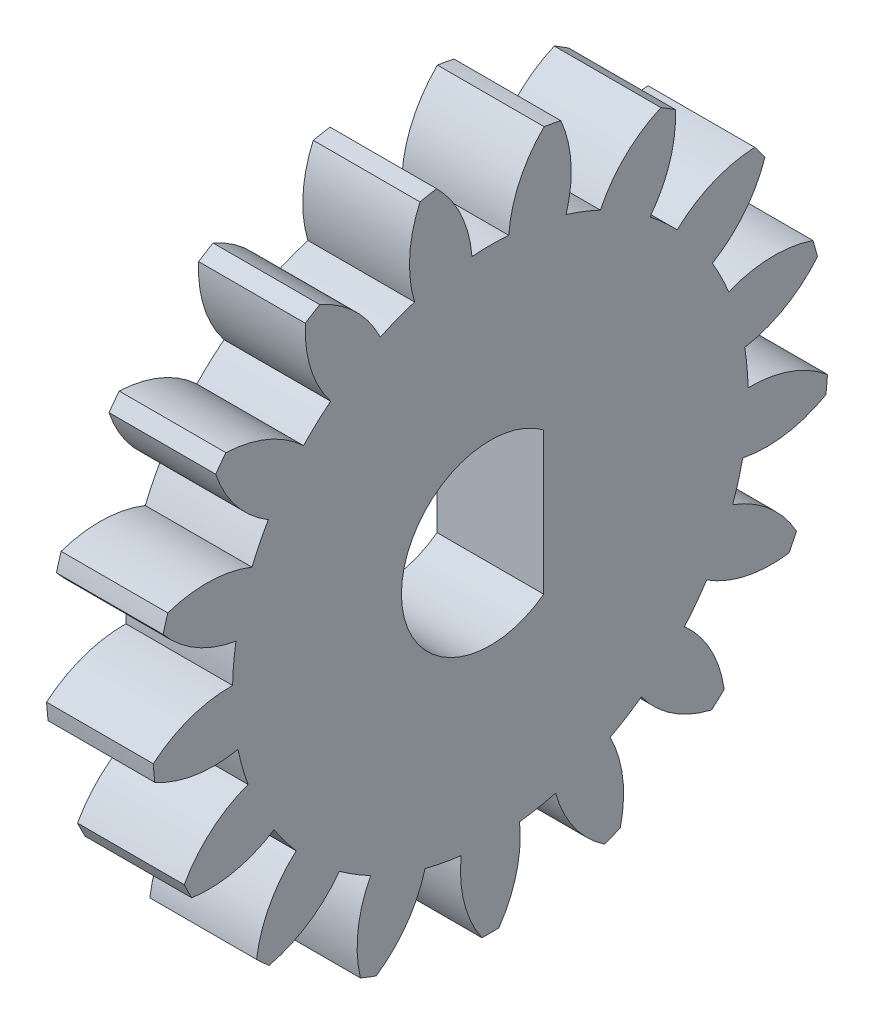
from build123d import *

# Parameters (mm, degrees)
BASPROSKE_W     = 3
BASPROSKE_H     = 9.5
TOOTHCUT_DEPTH  = 14.765899898
TEETHCUTS_COUNT = 17
TEETHCUTS_ANGLE = 338.823529412
BORSKE_R        = 2.5
BORE_DEPTH      = 50.0000508
EXTRUDE_1_DEPTH = 3


with BuildPart() as part:
    # BasProSke → Base-Revolve (revolve)
    with BuildSketch(Plane(origin=(0, 0, 0), x_dir=(1, 0, 0), z_dir=(0, 1, 0)), mode=Mode.PRIVATE) as base_revolve_sk:
        with Locations((1.5, 4.75)):
            Rectangle(BASPROSKE_W, BASPROSKE_H)
    revolve(base_revolve_sk.sketch.rotate(Axis((-10, 0, 0), (1, 0, 0)), 180), axis=Axis((-10, 0, 0), (1, 0, 0)))

    # TooCutSke → ToothCut (cut, through all)
    with BuildSketch(Plane(origin=(0, 0, 0), x_dir=(0, 0, -1), z_dir=(1, 0, 0))):
        with BuildLine():
            ThreePointArc((0.516861231, 7.23055015), (0, 7.249), (-0.516861231, 7.23055015))
            ThreePointArc((-0.516861231, 7.23055015), (-0.827352654, 8.408398361), (-1.533069197, 9.401220346))
            ThreePointArc((-1.533069197, 9.401220346), (0, 9.5254), (1.533069197, 9.401220346))
            ThreePointArc((1.533069197, 9.401220346), (0.827352654, 8.408398361), (0.516861231, 7.23055015))
        make_face()
    toothcut = extrude(amount=TOOTHCUT_DEPTH, mode=Mode.SUBTRACT)

    # TeethCuts: ToothCut ×17 about axis
    teethcuts_axis = Axis((-10, 0, 0), (1, 0, 0))
    for i in range(1, TEETHCUTS_COUNT):
        add(toothcut.rotate(teethcuts_axis, i * TEETHCUTS_ANGLE / (TEETHCUTS_COUNT - 1)), mode=Mode.SUBTRACT)

    # BorSke → Bore (cut, symmetric)
    with BuildSketch(Plane(origin=(0, 0, 0), x_dir=(0, 0, -1), z_dir=(1, 0, 0))):
        with Locations(Location((0, 0, 0), (0, 0, 180))):
            Circle(BORSKE_R)
    extrude(amount=BORE_DEPTH, both=True, mode=Mode.SUBTRACT)

    # 草图1 → 凸台-拉伸1 (add)
    with BuildSketch(Plane(origin=(3, 0, 0), x_dir=(0, 0, -1), z_dir=(1, 0, 0))):
        with BuildLine():
            Line((1.5, 2), (1.5, -2))
            ThreePointArc((1.5, -2), (2.5, 0), (1.5, 2))
        make_face()
    extrude(amount=-EXTRUDE_1_DEPTH)


solid = part.part
